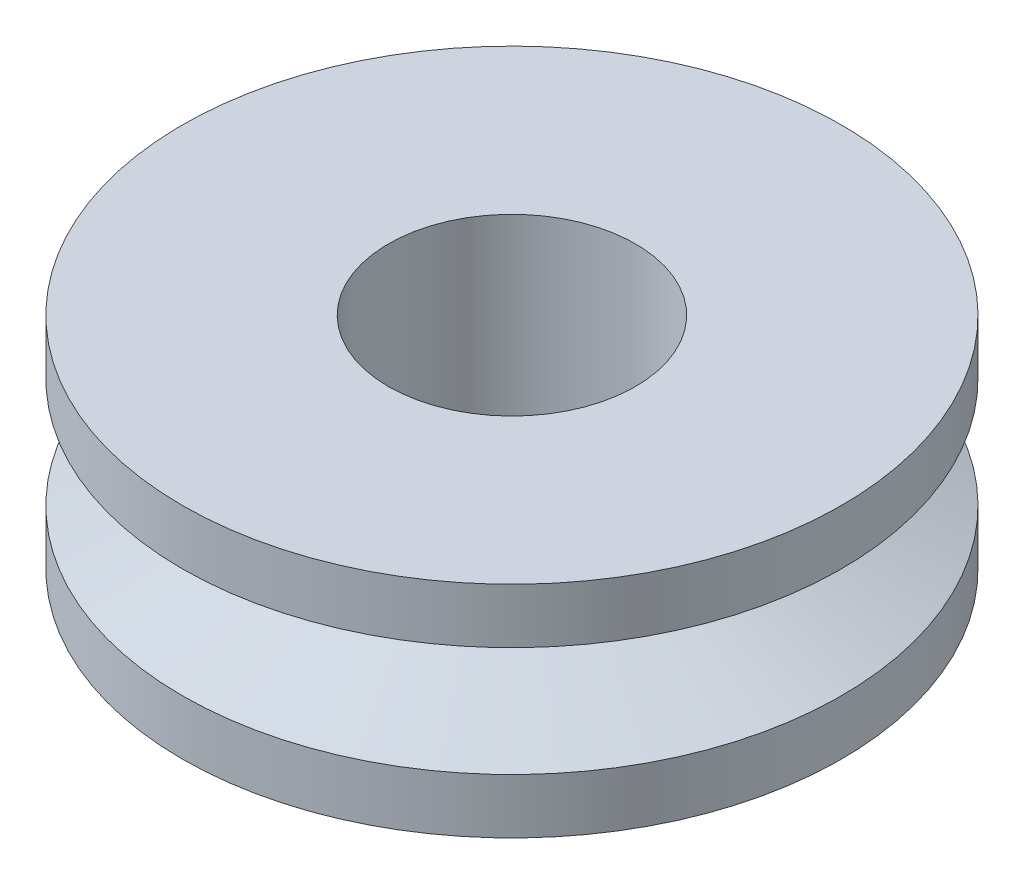
from build123d import *


with BuildPart() as part:
    # Sketch2 → Revolve2 (revolve)
    with BuildSketch(Plane.XY):
        Polygon((15, 5), (5.625, 5), (5.625, -5), (15, -5), (15, -2.5), (8.964466094, 0), (15, 2.5), align=None)
    revolve(axis=Axis((0, 14.320378175, 0), (0, -1, 0)))


solid = part.part
